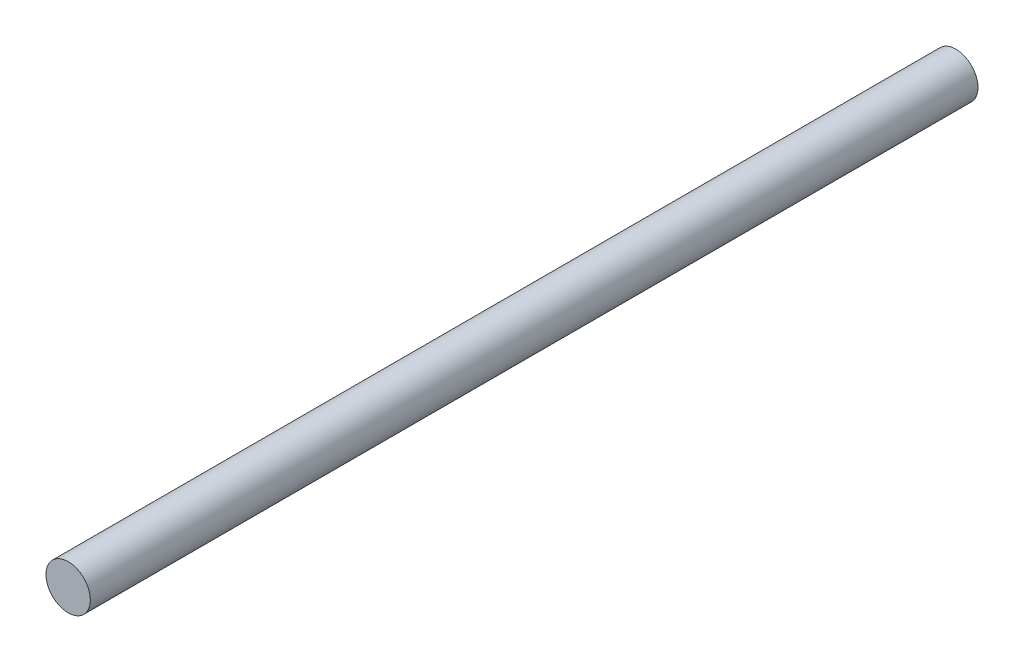
from build123d import *

# Parameters (mm, degrees)
ESQUISSE1_R        = 0.5
BOSS_EXTRU_1_DEPTH = 20


with BuildPart() as part:
    # Esquisse1 → Boss.-Extru.1 (new body)
    with BuildSketch(Plane.XY):
        Circle(ESQUISSE1_R)
    extrude(amount=BOSS_EXTRU_1_DEPTH)


solid = part.part
